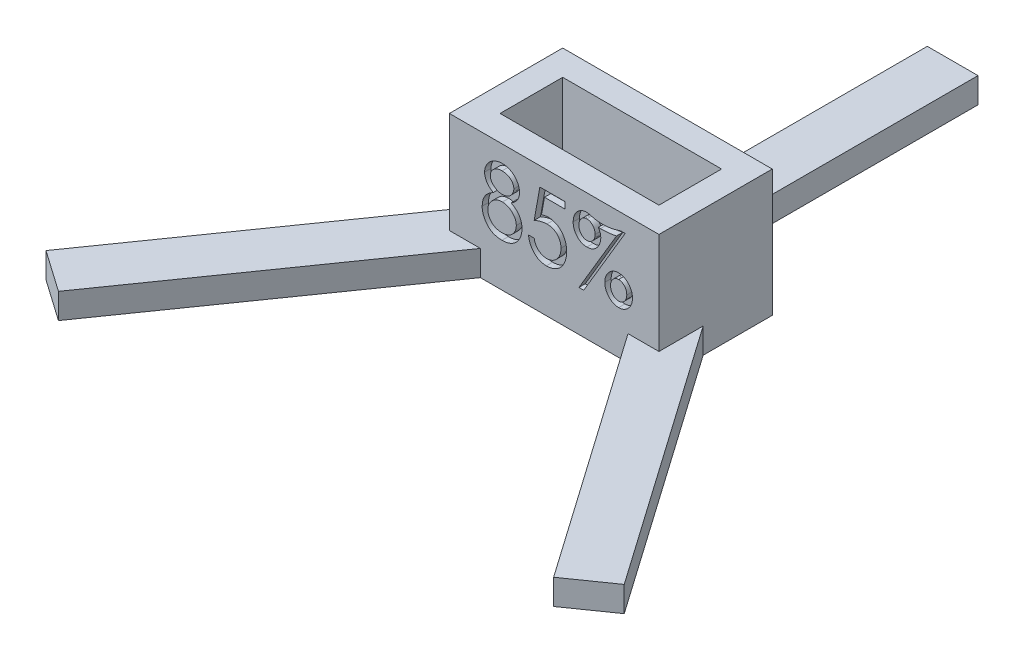
from build123d import *

# Parameters (mm, degrees)
SKETCH1_W             = 8
SKETCH1_H             = 45
BOSS_EXTRUDE1_DEPTH   = 4
BOSS_EXTRUDE1_2_DEPTH = 4
BOSS_EXTRUDE1_3_DEPTH = 4
SKETCH1_3_W           = 25.0698
SKETCH1_3_H           = 9.8806
BOSS_EXTRUDE2_DEPTH   = 20
CUT_EXTRUDE1_DEPTH    = 1


with BuildPart() as part:
    # Sketch1 → Boss-Extrude1 (new body)
    with BuildSketch(Plane(origin=(0, 0, 0), x_dir=(1, 0, 0), z_dir=(0, 1, 0))):
        with Locations((0, 31.4403)):
            Rectangle(SKETCH1_W, SKETCH1_H)
    extrude(amount=BOSS_EXTRUDE1_DEPTH)



with BuildPart() as body_2:
    # Sketch1 → Boss-Extrude1 2 (new body)
    with BuildSketch(Plane(origin=(0, 0, 0), x_dir=(1, 0, 0), z_dir=(0, 1, 0))):
        Polygon((-16.5349, -8.9403), (-16.5349, -1.966512818), (-45.622447813, -43.507836248), (-39.069231459, -48.096447738), (-11.651801645, -8.9403), align=None)
    extrude(amount=BOSS_EXTRUDE1_2_DEPTH)


with BuildPart() as body_3:
    # Sketch1 → Boss-Extrude1 3 (new body)
    with BuildSketch(Plane(origin=(0, 0, 0), x_dir=(1, 0, 0), z_dir=(0, 1, 0))):
        Polygon((45.622447813, -43.507836248), (16.5349, -1.966512818), (16.5349, -8.9403), (11.651801645, -8.9403), (39.069231459, -48.096447738), align=None)
    extrude(amount=BOSS_EXTRUDE1_3_DEPTH)


with BuildPart() as part_1:
    add(part.part)

    add(body_2.part)  # Boss-Extrude2 merges body 2

    add(body_3.part)  # Boss-Extrude2 merges body 3
    # Sketch1_3 → Boss-Extrude2 (add)
    with BuildSketch(Plane(origin=(0, 0, 0), x_dir=(1, 0, 0), z_dir=(0, 1, 0))):
        Polygon((-4, 8.9403), (-16.5349, 8.9403), (-16.5349, -1.966512818), (-16.5349, -8.9403), (-11.651801645, -8.9403), (11.651801645, -8.9403), (16.5349, -8.9403), (16.5349, -1.966512818), (16.5349, 8.9403), (4, 8.9403), align=None)
        Rectangle(SKETCH1_3_W, SKETCH1_3_H, mode=Mode.SUBTRACT)
    extrude(amount=BOSS_EXTRUDE2_DEPTH)

    # Sketch2 → Cut-Extrude1 (cut)
    # profile 1 of 4: a face of its own
    with BuildSketch(Plane.XY.offset(8.9403)):
        with BuildLine():
            add(Edge.make_bspline(
                [(-6.79314399, 12.649771541), (-6.717342821, 12.606981876), (-6.569116403, 12.523308248), (-6.358099072, 12.390611796), (-6.168281011, 12.247763488), (-5.990326983, 12.10806329), (-5.833426128, 11.958008496), (-5.69384615, 11.804486733), (-5.569455402, 11.647651561), (-5.431928233, 11.430856172), (-5.290676489, 11.145729516), (-5.166856952, 10.781790134), (-5.093651834, 10.393754983), (-5.084878424, 10.127380734), (-5.080403606, 9.991518336)],
                knots=[0, 0, 0, 0, 0.936542975, 1.831375574, 2.679144523, 3.491470365, 4.26389981, 5.011508052, 5.722891413, 6.414408021, 7.770248425, 9.135648072, 10.539056521, 12, 12, 12, 12], degree=3))
            add(Edge.make_bspline(
                [(-5.080403606, 9.991518336), (-5.081899375, 9.895244225), (-5.084859165, 9.704739536), (-5.121433878, 9.423690295), (-5.173934798, 9.150619568), (-5.25153255, 8.886238863), (-5.348322964, 8.630155498), (-5.471084701, 8.383936987), (-5.61165909, 8.144635704), (-5.723320139, 7.99534588), (-5.779522195, 7.920204233)],
                knots=[0, 0, 0, 0, 1.036424978, 2.050850602, 3.048199039, 4.029333599, 5.015202885, 5.993141774, 6.989893439, 8, 8, 8, 8], degree=3))
            add(Edge.make_bspline(
                [(-5.779522195, 7.920204233), (-5.853048351, 7.832942505), (-5.998529005, 7.660284312), (-6.248926024, 7.434473736), (-6.523979909, 7.244626836), (-6.822380899, 7.089899899), (-7.143229542, 6.969436448), (-7.486424218, 6.882861106), (-7.852726821, 6.833289668), (-8.104426454, 6.826121995), (-8.233448477, 6.822447823)],
                knots=[0, 0, 0, 0, 0.981131941, 1.941291689, 2.891287071, 3.849949701, 4.826493893, 5.834124351, 6.889765335, 8, 8, 8, 8], degree=3))
            add(Edge.make_bspline(
                [(-8.233448477, 6.822447823), (-8.357758165, 6.825769094), (-8.599837595, 6.832236904), (-8.951827599, 6.875291615), (-9.280150757, 6.952615089), (-9.587056124, 7.055191141), (-9.869512454, 7.192428296), (-10.127381592, 7.360610279), (-10.365085258, 7.555277126), (-10.572402784, 7.782690704), (-10.756881471, 8.025314606), (-10.918004948, 8.27678077), (-11.054779866, 8.533984287), (-11.16806958, 8.796890259), (-11.254214089, 9.066824902), (-11.316166757, 9.342278961), (-11.356193225, 9.623757239), (-11.360358672, 9.813766733), (-11.362454888, 9.909386925)],
                knots=[0, 0, 0, 0, 1.21096191, 2.358214982, 3.446884378, 4.49182925, 5.504198937, 6.49649756, 7.485058376, 8.488402548, 9.486228629, 10.451554982, 11.394331069, 12.321016062, 13.236400715, 14.150050479, 15.069033212, 16, 16, 16, 16], degree=3))
            add(Edge.make_bspline(
                [(-11.362454888, 9.909386925), (-11.357979159, 10.047911095), (-11.349201872, 10.319568828), (-11.275860259, 10.71619535), (-11.151526388, 11.089666503), (-11.011908354, 11.385521507), (-10.871219266, 11.609347488), (-10.745793796, 11.772933998), (-10.600744543, 11.93001289), (-10.439953765, 12.085826484), (-10.259741875, 12.234756225), (-10.061840718, 12.379963078), (-9.846051642, 12.520244233), (-9.692312765, 12.605931951), (-9.613656811, 12.649771541)],
                knots=[0, 0, 0, 0, 1.449072761, 2.841755515, 4.203119693, 5.559721925, 6.253850403, 6.966723721, 7.713721691, 8.489710117, 9.308452918, 10.158310275, 11.05775386, 12, 12, 12, 12], degree=3))
            add(Edge.make_bspline(
                [(-9.613656811, 12.649771541), (-9.721546601, 12.713300647), (-9.931900117, 12.83716381), (-10.210552362, 13.061044081), (-10.449486313, 13.305223447), (-10.642163586, 13.572526794), (-10.790957506, 13.856502582), (-10.898099184, 14.15151523), (-10.964991886, 14.457021292), (-10.973538318, 14.66466246), (-10.977839503, 14.769162567)],
                knots=[0, 0, 0, 0, 1.13273587, 2.208503431, 3.22641434, 4.218394485, 5.181414728, 6.120748945, 7.054224471, 8, 8, 8, 8], degree=3))
            add(Edge.make_bspline(
                [(-10.977839503, 14.769162567), (-10.972859065, 14.875672007), (-10.96286111, 15.089483876), (-10.891943087, 15.408228538), (-10.774158317, 15.721323692), (-10.613955995, 16.027114013), (-10.414515779, 16.316079533), (-10.173033371, 16.574221857), (-9.897963089, 16.801103234), (-9.590070232, 16.991311033), (-9.259256025, 17.146638844), (-8.909647289, 17.253491841), (-8.548051994, 17.323246669), (-8.301882969, 17.331229987), (-8.177358734, 17.335268336)],
                knots=[0, 0, 0, 0, 0.910776501, 1.828333955, 2.778985199, 3.765162585, 4.774507301, 5.772785072, 6.779119179, 7.815669498, 8.860886553, 9.896066783, 10.935728504, 12, 12, 12, 12], degree=3))
            add(Edge.make_bspline(
                [(-8.177358734, 17.335268336), (-8.056197479, 17.331126636), (-7.816702837, 17.322939902), (-7.464159268, 17.254608613), (-7.126533085, 17.141845264), (-6.805938071, 16.986952896), (-6.507701965, 16.796387809), (-6.241876755, 16.568719073), (-6.0108045, 16.308772563), (-5.816312046, 16.022201053), (-5.659529534, 15.716142652), (-5.546688189, 15.398399565), (-5.477621904, 15.071948153), (-5.469228609, 14.851621507), (-5.46501899, 14.741117695)],
                knots=[0, 0, 0, 0, 1.046778402, 2.069125308, 3.091390723, 4.116406946, 5.139600975, 6.142665277, 7.132132783, 8.137635919, 9.129004421, 10.096677816, 11.045397548, 12, 12, 12, 12], degree=3))
            add(Edge.make_bspline(
                [(-5.46501899, 14.741117695), (-5.468535113, 14.632628895), (-5.475433061, 14.419795054), (-5.53969705, 14.110024637), (-5.644106009, 13.818148346), (-5.792819528, 13.545730281), (-5.980297574, 13.290364961), (-6.213858156, 13.057428679), (-6.483553962, 12.83716416), (-6.687963312, 12.71343665), (-6.79314399, 12.649771541)],
                knots=[0, 0, 0, 0, 0.997542021, 1.95698265, 2.897938278, 3.841179291, 4.803666238, 5.803250932, 6.86964291, 8, 8, 8, 8], degree=3))
        make_face()
        with BuildLine():
            add(Edge.make_bspline(
                [(-8.225435657, 16.30962731), (-8.290912687, 16.307793004), (-8.418832269, 16.304209401), (-8.607363259, 16.284741015), (-8.786789674, 16.24829672), (-8.958559026, 16.199359777), (-9.119361587, 16.13079197), (-9.274759356, 16.054583034), (-9.419270673, 15.958680129), (-9.554596332, 15.851378111), (-9.677433576, 15.734816091), (-9.785032082, 15.611564723), (-9.875832665, 15.482753113), (-9.950617938, 15.34781485), (-10.008543785, 15.207208846), (-10.051704369, 15.061773971), (-10.075820301, 14.910199221), (-10.078861698, 14.807304836), (-10.080403606, 14.755140131)],
                knots=[0, 0, 0, 0, 1.167930736, 2.281734702, 3.374655602, 4.42968456, 5.460169067, 6.487966878, 7.511825295, 8.545812643, 9.564951514, 10.527197576, 11.458821733, 12.370211683, 13.272454276, 14.165535204, 15.069975329, 16, 16, 16, 16], degree=3))
            add(Edge.make_bspline(
                [(-10.080403606, 14.755140131), (-10.07930648, 14.702898692), (-10.077137612, 14.599624498), (-10.04620701, 14.447492299), (-10.00311841, 14.298611391), (-9.940331711, 14.153351836), (-9.858432485, 14.013042946), (-9.763483857, 13.873241147), (-9.644563208, 13.742150007), (-9.514888461, 13.612749445), (-9.372108199, 13.494122082), (-9.222058137, 13.388867515), (-9.063594914, 13.302354108), (-8.900658599, 13.230859361), (-8.73202489, 13.17326283), (-8.557436941, 13.133844185), (-8.376395357, 13.108931668), (-8.25356236, 13.10598884), (-8.19138117, 13.104499105)],
                knots=[0, 0, 0, 0, 0.905852599, 1.790746938, 2.68614417, 3.595331889, 4.530413024, 5.505287501, 6.52435105, 7.598740087, 8.685763206, 9.744258785, 10.777285004, 11.815960297, 12.831917038, 13.867284544, 14.920365135, 16, 16, 16, 16], degree=3))
            add(Edge.make_bspline(
                [(-8.19138117, 13.104499105), (-8.111708856, 13.106992232), (-7.953124773, 13.111954687), (-7.719678808, 13.158153552), (-7.493148145, 13.230803817), (-7.27570659, 13.33063158), (-7.072220968, 13.455259411), (-6.890792855, 13.60477498), (-6.732127815, 13.774513192), (-6.601431068, 13.964627728), (-6.496904861, 14.164167678), (-6.418065635, 14.366544508), (-6.37304163, 14.570876173), (-6.365960138, 14.707530159), (-6.362454888, 14.775172182)],
                knots=[0, 0, 0, 0, 1.04622229, 2.082457431, 3.114969114, 4.167467583, 5.219673264, 6.242289877, 7.248351568, 8.263597399, 9.264670006, 10.203562472, 11.110785765, 12, 12, 12, 12], degree=3))
            add(Edge.make_bspline(
                [(-6.362454888, 14.775172182), (-6.3641065, 14.822667741), (-6.367380897, 14.916829819), (-6.390200437, 15.05580787), (-6.426642996, 15.1921878), (-6.478473004, 15.32614402), (-6.547380443, 15.456494578), (-6.630476918, 15.583419293), (-6.727281693, 15.708273694), (-6.837850487, 15.829633454), (-6.963707586, 15.941523354), (-7.103491006, 16.041321482), (-7.257743559, 16.124734447), (-7.425526743, 16.193670259), (-7.606607653, 16.244536555), (-7.800679409, 16.28347665), (-8.00861999, 16.304661649), (-8.15194132, 16.307944092), (-8.225435657, 16.30962731)],
                knots=[0, 0, 0, 0, 0.846273469, 1.677775159, 2.503379903, 3.358642367, 4.231605182, 5.126121923, 6.059228345, 7.044670925, 8.047775682, 9.054896115, 10.098683671, 11.166083855, 12.28092389, 13.445529808, 14.69008269, 16, 16, 16, 16], degree=3))
        make_face(mode=Mode.SUBTRACT)
        with BuildLine():
            add(Edge.make_bspline(
                [(-8.173352323, 12.078858079), (-8.252943304, 12.077246118), (-8.409460541, 12.074076166), (-8.63847039, 12.039795405), (-8.858953053, 11.990812716), (-9.069632841, 11.919047228), (-9.269320925, 11.822899602), (-9.460138119, 11.709573911), (-9.639379398, 11.573033466), (-9.808307448, 11.420837973), (-9.960501335, 11.253430919), (-10.096903695, 11.079358725), (-10.208271089, 10.895214911), (-10.304418314, 10.706825431), (-10.376683093, 10.509673877), (-10.425776592, 10.305168193), (-10.46006939, 10.094829751), (-10.463359383, 9.951593218), (-10.46501899, 9.879338849)],
                knots=[0, 0, 0, 0, 1.081539399, 2.126868595, 3.142349074, 4.150290619, 5.145429903, 6.15144715, 7.163022546, 8.204479408, 9.239224426, 10.236350348, 11.206610885, 12.160933525, 13.108971242, 14.05378537, 15.018249692, 16, 16, 16, 16], degree=3))
            add(Edge.make_bspline(
                [(-10.46501899, 9.879338849), (-10.461505994, 9.78960063), (-10.454550832, 9.611933517), (-10.399881309, 9.349091934), (-10.311803425, 9.094500134), (-10.188906577, 8.850374773), (-10.037544954, 8.621618915), (-9.848906243, 8.422753551), (-9.638593461, 8.245565143), (-9.397695534, 8.102193712), (-9.134341697, 7.986400334), (-8.847847127, 7.908894096), (-8.543232965, 7.855824547), (-8.3331824, 7.850711578), (-8.225435657, 7.848088849)],
                knots=[0, 0, 0, 0, 0.953900318, 1.888567877, 2.843208308, 3.812011761, 4.789111247, 5.749021607, 6.71753862, 7.705420928, 8.720131869, 9.767960352, 10.855061389, 12, 12, 12, 12], degree=3))
            add(Edge.make_bspline(
                [(-8.225435657, 7.848088849), (-8.141874797, 7.849932222), (-7.978198582, 7.85354296), (-7.739458936, 7.884116341), (-7.513247802, 7.933862681), (-7.300885756, 8.004505174), (-7.100009812, 8.09171514), (-6.915686158, 8.20420135), (-6.74096948, 8.331772953), (-6.58523011, 8.482559344), (-6.443198593, 8.644061345), (-6.318545232, 8.814050961), (-6.214158896, 8.991627178), (-6.126895253, 9.174156444), (-6.060751405, 9.364461895), (-6.012325822, 9.56083623), (-5.983907754, 9.764996797), (-5.979882683, 9.90328999), (-5.977839503, 9.97348949)],
                knots=[0, 0, 0, 0, 1.159357446, 2.270910543, 3.334408313, 4.368922933, 5.372934548, 6.366282269, 7.359759672, 8.369273697, 9.367494498, 10.342516416, 11.289792923, 12.222542171, 13.145805194, 14.080853556, 15.025815257, 16, 16, 16, 16], degree=3))
            add(Edge.make_bspline(
                [(-5.977839503, 9.97348949), (-5.97967542, 10.041718102), (-5.983293659, 10.176183595), (-6.014836669, 10.374845217), (-6.064553677, 10.567632297), (-6.135393126, 10.754819812), (-6.225680497, 10.936694727), (-6.339302593, 11.110370561), (-6.46981, 11.279925017), (-6.619308676, 11.440079151), (-6.781270345, 11.590076001), (-6.955989884, 11.719607596), (-7.137569772, 11.831849629), (-7.328611352, 11.921813485), (-7.527914521, 11.992421876), (-7.735978969, 12.042545195), (-7.952083393, 12.073186122), (-8.099133817, 12.076955579), (-8.173352323, 12.078858079)],
                knots=[0, 0, 0, 0, 0.971444992, 1.914531533, 2.858193596, 3.803436534, 4.760618253, 5.744833788, 6.755181074, 7.805273357, 8.86236533, 9.895429839, 10.898766981, 11.898716369, 12.897579249, 13.905819635, 14.943036437, 16, 16, 16, 16], degree=3))
        make_face(mode=Mode.SUBTRACT)
    # profile 2 of 4: a face of its own
    with BuildSketch(Plane.XY.offset(8.9403)):
        with BuildLine():
            Line((1.714468189, 17.078858079), (1.714468189, 16.053217054))
            Line((1.714468189, 16.053217054), (-1.528720913, 16.053217054))
            Line((-1.528720913, 16.053217054), (-2.001477323, 13.429018336))
            add(Edge.make_bspline(
                [(-2.001477323, 13.429018336), (-1.90430502, 13.457582178), (-1.716013869, 13.512930446), (-1.437900942, 13.573784027), (-1.173739553, 13.60918937), (-1.002640679, 13.614666199), (-0.919746554, 13.617319618)],
                knots=[0, 0, 0, 0, 1.102707905, 2.136721407, 3.097277234, 4, 4, 4, 4], degree=3))
            add(Edge.make_bspline(
                [(-0.919746554, 13.617319618), (-0.816736219, 13.614967598), (-0.615066104, 13.610362895), (-0.319849896, 13.564062831), (-0.038329361, 13.492730917), (0.229663519, 13.391825494), (0.484295704, 13.26323882), (0.723294574, 13.10333747), (0.949507245, 12.915983341), (1.15786181, 12.69958041), (1.348984333, 12.46345469), (1.517295425, 12.209160788), (1.65705724, 11.938051125), (1.772017357, 11.650871808), (1.862303964, 11.347875642), (1.925780897, 11.028007262), (1.964787874, 10.692278761), (1.968820735, 10.463047596), (1.970878446, 10.346085643)],
                knots=[0, 0, 0, 0, 1.010628668, 1.97857427, 2.926238053, 3.857732153, 4.784206679, 5.720601656, 6.674976368, 7.662461082, 8.664805768, 9.653942959, 10.650870456, 11.653986639, 12.686928979, 13.750194809, 14.852068795, 16, 16, 16, 16], degree=3))
            add(Edge.make_bspline(
                [(1.970878446, 10.346085643), (1.965977564, 10.184189043), (1.956319252, 9.865134681), (1.876691617, 9.39726742), (1.742813832, 8.950587004), (1.590207339, 8.596419511), (1.442760067, 8.329704314), (1.324942499, 8.140211568), (1.196199071, 7.96421349), (1.059966488, 7.798781844), (0.913238259, 7.646190229), (0.756642199, 7.505488323), (0.590191173, 7.377464432), (0.415398023, 7.261268939), (0.233763192, 7.155894646), (0.042207466, 7.069117587), (-0.154488531, 6.991615562), (-0.358961245, 6.930154716), (-0.569753259, 6.881659643), (-0.787422264, 6.848581542), (-1.012029717, 6.824634201), (-1.164738882, 6.823184017), (-1.24226258, 6.822447823)],
                knots=[0, 0, 0, 0, 1.817942315, 3.582672045, 5.312817344, 7.046390462, 7.902497116, 8.735010984, 9.551245316, 10.350340788, 11.14083426, 11.92700933, 12.713220188, 13.497567984, 14.283778841, 15.069130373, 15.857592503, 16.657286298, 17.465240455, 18.285360574, 19.129553296, 20, 20, 20, 20], degree=3))
            add(Edge.make_bspline(
                [(-1.24226258, 6.822447823), (-1.333899524, 6.824448319), (-1.51465353, 6.828394301), (-1.779245502, 6.86885474), (-2.034256198, 6.927433085), (-2.277406261, 7.015112672), (-2.511339199, 7.124640972), (-2.731542947, 7.262505215), (-2.942226961, 7.421843233), (-3.139105541, 7.605469321), (-3.320238522, 7.809603204), (-3.485308052, 8.028086198), (-3.630569952, 8.261870526), (-3.754128346, 8.510450465), (-3.858948936, 8.773182373), (-3.944976623, 9.049690479), (-4.011352848, 9.341171523), (-4.040128616, 9.541223751), (-4.05476258, 9.642960643)],
                knots=[0, 0, 0, 0, 1.003116473, 1.978648716, 2.926104392, 3.865449161, 4.804537555, 5.750523693, 6.705881415, 7.694490351, 8.694401117, 9.692169023, 10.690874996, 11.704999753, 12.729205104, 13.786546159, 14.874344384, 16, 16, 16, 16], degree=3))
            Line((-4.05476258, 9.642960643), (-3.157326682, 9.642960643))
            add(Edge.make_bspline(
                [(-3.157326682, 9.642960643), (-3.137743706, 9.547701349), (-3.100206545, 9.365105845), (-3.017392655, 9.107815566), (-2.915800349, 8.878423403), (-2.794520701, 8.674864181), (-2.65187142, 8.494675692), (-2.485567344, 8.337806021), (-2.302920355, 8.192146973), (-2.09701375, 8.073497216), (-1.880984452, 7.971432521), (-1.654632251, 7.903040037), (-1.424549752, 7.855274998), (-1.268549209, 7.850491789), (-1.190179247, 7.848088849)],
                knots=[0, 0, 0, 0, 1.202539977, 2.305060038, 3.336811461, 4.300249956, 5.229209465, 6.169887062, 7.123427807, 8.112385324, 9.103101112, 10.072507195, 11.031685809, 12, 12, 12, 12], degree=3))
            add(Edge.make_bspline(
                [(-1.190179247, 7.848088849), (-1.113917298, 7.850452324), (-0.963298584, 7.85512023), (-0.741876429, 7.890632632), (-0.528151514, 7.945266471), (-0.324923106, 8.028417257), (-0.12626271, 8.126442496), (0.059144689, 8.256332747), (0.241426905, 8.40131957), (0.409202511, 8.571796), (0.565186907, 8.756450401), (0.702444644, 8.955199061), (0.816118186, 9.166809939), (0.911824364, 9.388140416), (0.98309757, 9.621576666), (1.035190624, 9.865482539), (1.068517404, 10.120806604), (1.071779635, 10.295233093), (1.073442548, 10.384146541)],
                knots=[0, 0, 0, 0, 0.966892467, 1.909629934, 2.8382218, 3.758315477, 4.690146358, 5.641556776, 6.623066209, 7.641204016, 8.669263481, 9.686520165, 10.698438552, 11.711596797, 12.740318951, 13.788555981, 14.872722182, 16, 16, 16, 16], degree=3))
            add(Edge.make_bspline(
                [(1.073442548, 10.384146541), (1.071475376, 10.464363213), (1.067626983, 10.621291665), (1.038822854, 10.850477032), (0.993655832, 11.06813315), (0.927079898, 11.27430383), (0.840235432, 11.468122053), (0.738301242, 11.65252167), (0.615154602, 11.82385519), (0.472534628, 11.98065131), (0.317532675, 12.125864632), (0.146343192, 12.250468833), (-0.038082379, 12.354200737), (-0.232464382, 12.444734308), (-0.442533126, 12.508985951), (-0.663457401, 12.557831999), (-0.897007289, 12.585644169), (-1.056562108, 12.589637809), (-1.138095913, 12.591678592)],
                knots=[0, 0, 0, 0, 1.093612449, 2.139441871, 3.144892665, 4.12105543, 5.08718674, 6.037047387, 6.989697133, 7.956857702, 8.923418003, 9.881405251, 10.835750608, 11.805607787, 12.799113192, 13.824284988, 14.888192007, 16, 16, 16, 16], degree=3))
            add(Edge.make_bspline(
                [(-1.138095913, 12.591678592), (-1.209606935, 12.59006207), (-1.356346481, 12.586744991), (-1.581780984, 12.561046444), (-1.817876231, 12.521089125), (-2.065104964, 12.464118015), (-2.323167043, 12.392063877), (-2.592192486, 12.302944002), (-2.872447857, 12.199385682), (-3.060813436, 12.119691266), (-3.157326682, 12.078858079)],
                knots=[0, 0, 0, 0, 0.81831526, 1.679170654, 2.59384348, 3.557915884, 4.581464615, 5.659350651, 6.800716828, 8, 8, 8, 8], degree=3))
            Line((-3.157326682, 12.078858079), (-2.259890785, 17.078858079))
            Line((-2.259890785, 17.078858079), (1.714468189, 17.078858079))
        make_face()
    # profile 3 of 4: a face of its own
    with BuildSketch(Plane.XY.offset(8.9403)):
        with BuildLine():
            Line((11.201647677, 17.463473464), (4.663186138, 6.437832438))
            Line((4.663186138, 6.437832438), (3.903971394, 6.437832438))
            Line((3.903971394, 6.437832438), (9.845477805, 16.453858079))
            add(Edge.make_bspline(
                [(9.845477805, 16.453858079), (9.75688223, 16.431518488), (9.575308844, 16.385734314), (9.292508186, 16.334264674), (8.997018565, 16.284700355), (8.686105922, 16.247631872), (8.361539422, 16.216954837), (8.022028585, 16.1987271), (7.668808352, 16.182827787), (7.428297516, 16.181897495), (7.305413702, 16.181422182)],
                knots=[0, 0, 0, 0, 0.855912764, 1.754161863, 2.692276577, 3.66314188, 4.687322541, 5.746584714, 6.848666156, 8, 8, 8, 8], degree=3))
            Line((7.305413702, 16.181422182), (6.96486883, 16.187431797))
            add(Edge.make_bspline(
                [(6.96486883, 16.187431797), (7.024651477, 16.091524452), (7.141735517, 15.903690356), (7.263633321, 15.598419432), (7.342312218, 15.285312212), (7.351099066, 15.072110192), (7.35549383, 14.965476669)],
                knots=[0, 0, 0, 0, 1.040152756, 2.037134388, 3.018267853, 4, 4, 4, 4], degree=3))
            add(Edge.make_bspline(
                [(7.35549383, 14.965476669), (7.353435627, 14.88993817), (7.349341624, 14.73968338), (7.320663929, 14.517828514), (7.274539045, 14.301192776), (7.208998809, 14.090870289), (7.12114975, 13.88824989), (7.018762512, 13.689929699), (6.896820512, 13.497624932), (6.755028918, 13.315531009), (6.601590732, 13.145043681), (6.43059455, 12.997699939), (6.249737759, 12.870619498), (6.053517423, 12.770040102), (5.847827911, 12.689181124), (5.628426693, 12.633421156), (5.397473181, 12.59864171), (5.238900363, 12.594031344), (5.157977805, 12.591678592)],
                knots=[0, 0, 0, 0, 1.005575621, 2.000205929, 2.973185489, 3.951673136, 4.927572614, 5.90972857, 6.920908292, 7.954047531, 8.979662321, 9.969034214, 10.952999114, 11.915278637, 12.897595523, 13.889480591, 14.922964025, 16, 16, 16, 16], degree=3))
            add(Edge.make_bspline(
                [(5.157977805, 12.591678592), (5.083066899, 12.593360514), (4.935865633, 12.59666552), (4.71965698, 12.630035664), (4.512479854, 12.683426505), (4.315028034, 12.761097654), (4.125449699, 12.856779573), (3.946057444, 12.97671146), (3.775833419, 13.117205833), (3.616503895, 13.277095881), (3.470898977, 13.451625858), (3.345192438, 13.639137714), (3.234892812, 13.833447464), (3.149375288, 14.039935341), (3.081471894, 14.254483203), (3.030065884, 14.477970812), (3.002824327, 14.711055725), (2.998640292, 14.869259858), (2.996519471, 14.949451028)],
                knots=[0, 0, 0, 0, 1.008398907, 1.981521851, 2.939267593, 3.884685526, 4.834031687, 5.794476735, 6.784904661, 7.802527834, 8.83094575, 9.841308357, 10.839871351, 11.835513377, 12.845355375, 13.868765724, 14.919711099, 16, 16, 16, 16], degree=3))
            add(Edge.make_bspline(
                [(2.996519471, 14.949451028), (3.000007433, 15.056508295), (3.006873234, 15.267242822), (3.060396608, 15.575236968), (3.146238185, 15.868106916), (3.267640762, 16.14350992), (3.418010641, 16.40032385), (3.603567009, 16.630149021), (3.814235292, 16.837262116), (4.054335257, 17.010350331), (4.307193071, 17.155396712), (4.569959751, 17.25752285), (4.835480646, 17.324243364), (5.014698044, 17.331604722), (5.103891266, 17.335268336)],
                knots=[0, 0, 0, 0, 1.092215168, 2.149946973, 3.180744331, 4.200099484, 5.214681398, 6.208844029, 7.206551423, 8.220766995, 9.221704991, 10.173472071, 11.090970441, 12, 12, 12, 12], degree=3))
            add(Edge.make_bspline(
                [(5.103891266, 17.335268336), (5.148049067, 17.332714136), (5.249678302, 17.326835643), (5.419367892, 17.295782336), (5.62613096, 17.25014249), (5.774514428, 17.207943735), (5.855093189, 17.185027951)],
                knots=[0, 0, 0, 0, 0.690746528, 1.589753997, 2.691130206, 4, 4, 4, 4], degree=3))
            add(Edge.make_bspline(
                [(5.855093189, 17.185027951), (5.990841103, 17.14889161), (6.26551708, 17.075772366), (6.691698616, 17.003516127), (7.13412693, 16.957811272), (7.434836062, 16.953067192), (7.587865625, 16.950652951)],
                knots=[0, 0, 0, 0, 0.960518299, 1.943538547, 2.953475758, 4, 4, 4, 4], degree=3))
            add(Edge.make_bspline(
                [(7.587865625, 16.950652951), (7.701420716, 16.951509364), (7.924709447, 16.95319337), (8.254636187, 16.975383063), (8.574995883, 17.003636279), (8.895386998, 17.049088548), (9.233505611, 17.11599988), (9.607523476, 17.206982533), (10.027466006, 17.324155582), (10.321141982, 17.415274432), (10.47648742, 17.463473464)],
                knots=[0, 0, 0, 0, 0.924375097, 1.817642348, 2.691321289, 3.542448545, 4.450874239, 5.49655074, 6.675753369, 8, 8, 8, 8], degree=3))
            Line((10.47648742, 17.463473464), (11.201647677, 17.463473464))
        make_face()
        with BuildLine():
            add(Edge.make_bspline(
                [(5.174003446, 16.437832438), (5.087878694, 16.432387168), (4.918417005, 16.421672888), (4.674485007, 16.337206283), (4.452629596, 16.197659233), (4.2589393, 16.006578404), (4.098029998, 15.780710215), (3.979336482, 15.527155337), (3.907272314, 15.250527732), (3.898466301, 15.05805987), (3.893955369, 14.959467054)],
                knots=[0, 0, 0, 0, 0.951178476, 1.871567791, 2.820592491, 3.828833882, 4.861882757, 5.873123466, 6.91049474, 8, 8, 8, 8], degree=3))
            add(Edge.make_bspline(
                [(3.893955369, 14.959467054), (3.898356753, 14.860837012), (3.906920017, 14.668943958), (3.98030103, 14.392850377), (4.096834226, 14.138831912), (4.25927635, 13.914597668), (4.451949515, 13.724383274), (4.676131947, 13.591113468), (4.917725629, 13.501944262), (5.087741994, 13.493432908), (5.174003446, 13.48911449)],
                knots=[0, 0, 0, 0, 1.09192248, 2.124427164, 3.144622361, 4.173937012, 5.179276371, 6.122653022, 7.047487717, 8, 8, 8, 8], degree=3))
            add(Edge.make_bspline(
                [(5.174003446, 13.48911449), (5.260241018, 13.493469281), (5.430210316, 13.502052324), (5.671608898, 13.590493591), (5.894429215, 13.725647462), (6.088795192, 13.9143081), (6.252910047, 14.138784928), (6.372132959, 14.392355684), (6.444960996, 14.66900266), (6.453611638, 14.860856941), (6.458057933, 14.959467054)],
                knots=[0, 0, 0, 0, 0.951739036, 1.875822953, 2.812113807, 3.82198859, 4.854794862, 5.87729744, 6.908963939, 8, 8, 8, 8], degree=3))
            add(Edge.make_bspline(
                [(6.458057933, 14.959467054), (6.453501832, 15.058039551), (6.444607645, 15.250467748), (6.373103549, 15.527657695), (6.251704361, 15.780742637), (6.089140554, 16.006874673), (5.893724248, 16.196384427), (5.673264443, 16.337817623), (5.429516877, 16.421563869), (5.260103595, 16.432350432), (5.174003446, 16.437832438)],
                knots=[0, 0, 0, 0, 1.088619988, 2.125148351, 3.138716664, 4.175218747, 5.187953588, 6.129952941, 7.049594399, 8, 8, 8, 8], degree=3))
        make_face(mode=Mode.SUBTRACT)
    # profile 4 of 4: a face of its own
    with BuildSketch(Plane.XY.offset(8.9403)):
        with BuildLine():
            add(Edge.make_bspline(
                [(10.176006651, 11.566037567), (10.24960697, 11.564502446), (10.395623514, 11.561456904), (10.609548109, 11.525358702), (10.816019048, 11.471940278), (11.013482088, 11.394999395), (11.202956733, 11.296314833), (11.383287507, 11.174895472), (11.55757045, 11.034059286), (11.718904701, 10.870712224), (11.86809549, 10.694244349), (12.000191424, 10.507587384), (12.107523668, 10.309512233), (12.199227487, 10.104477202), (12.268962849, 9.889478945), (12.31919447, 9.665543311), (12.349898773, 9.432810597), (12.353612424, 9.274464055), (12.35549383, 9.194242695)],
                knots=[0, 0, 0, 0, 0.986039861, 1.956216137, 2.901059252, 3.842288536, 4.791534564, 5.760139168, 6.753107791, 7.791550277, 8.833769631, 9.849808566, 10.851780974, 11.850105389, 12.858221254, 13.877097411, 14.92449729, 16, 16, 16, 16], degree=3))
            add(Edge.make_bspline(
                [(12.35549383, 9.194242695), (12.353612573, 9.114021237), (12.349899217, 8.955674504), (12.319192768, 8.722943186), (12.268969017, 8.499002434), (12.199204802, 8.28402294), (12.107607581, 8.078918585), (11.999612395, 7.880621594), (11.868653842, 7.692567209), (11.719631927, 7.515639739), (11.556101305, 7.354776403), (11.384701482, 7.211021846), (11.202197764, 7.092616448), (11.013595917, 6.993323477), (10.815988566, 6.916588632), (10.609556491, 6.863114721), (10.395621356, 6.827031568), (10.249606247, 6.823983976), (10.176006651, 6.822447823)],
                knots=[0, 0, 0, 0, 1.075383163, 2.122666619, 3.141429524, 4.149433332, 5.147646778, 6.149507813, 7.172785576, 8.214889083, 9.2469043, 10.245438947, 11.208998036, 12.158138551, 13.099263214, 14.044001305, 15.014069742, 16, 16, 16, 16], degree=3))
            add(Edge.make_bspline(
                [(10.176006651, 6.822447823), (10.102407055, 6.823983976), (9.956391946, 6.827031568), (9.742456811, 6.863114721), (9.536024736, 6.916588632), (9.338417385, 6.993323477), (9.149815538, 7.092616448), (8.96731182, 7.211021846), (8.795911996, 7.354776403), (8.632381374, 7.515639739), (8.483359459, 7.692567209), (8.352400906, 7.880621594), (8.24440572, 8.078918585), (8.152808499, 8.28402294), (8.083044285, 8.499002434), (8.032820534, 8.722943186), (8.002114085, 8.955674504), (7.998400728, 9.114021237), (7.996519471, 9.194242695)],
                knots=[0, 0, 0, 0, 0.985930258, 1.955998695, 2.900736786, 3.841861449, 4.791001964, 5.754561053, 6.7530957, 7.785110917, 8.827214424, 9.850492187, 10.852353222, 11.850566668, 12.858570476, 13.877333381, 14.924616837, 16, 16, 16, 16], degree=3))
            add(Edge.make_bspline(
                [(7.996519471, 9.194242695), (7.998400878, 9.274464055), (8.002114529, 9.432810597), (8.032818832, 9.665543311), (8.083050452, 9.889478945), (8.152785814, 10.104477202), (8.244489633, 10.309512233), (8.351821877, 10.507587384), (8.483917812, 10.694244349), (8.633108601, 10.870712224), (8.794442852, 11.034059286), (8.968725795, 11.174895472), (9.149056568, 11.296314833), (9.338531214, 11.394999395), (9.535994254, 11.471940278), (9.742465192, 11.525358702), (9.956389787, 11.561456904), (10.102406331, 11.564502446), (10.176006651, 11.566037567)],
                knots=[0, 0, 0, 0, 1.07550271, 2.122902589, 3.141778746, 4.149894611, 5.148219026, 6.150191434, 7.166230369, 8.208449723, 9.246892209, 10.239860832, 11.208465436, 12.157711464, 13.098940748, 14.043783863, 15.013960139, 16, 16, 16, 16], degree=3))
        make_face()
        with BuildLine():
            add(Edge.make_bspline(
                [(10.174003446, 10.668601669), (10.087768185, 10.664240482), (9.917803442, 10.655644833), (9.675497945, 10.566976812), (9.452565287, 10.430982515), (9.259164234, 10.241284805), (9.0968978, 10.016827422), (8.979888193, 9.762316914), (8.90716615, 9.485357883), (8.89843034, 9.292853976), (8.893955369, 9.194242695)],
                knots=[0, 0, 0, 0, 0.951201534, 1.874763567, 2.820692533, 3.824648448, 4.852546663, 5.871337972, 6.909580111, 8, 8, 8, 8], degree=3))
            add(Edge.make_bspline(
                [(8.893955369, 9.194242695), (8.89843034, 9.095631414), (8.90716615, 8.903127506), (8.979888193, 8.626168475), (9.0968978, 8.371657967), (9.259164234, 8.147200584), (9.452565287, 7.957502874), (9.675497945, 7.821508578), (9.917803442, 7.732840556), (10.087768185, 7.724244907), (10.174003446, 7.71988372)],
                knots=[0, 0, 0, 0, 1.090419889, 2.128662028, 3.147453337, 4.175351552, 5.179307467, 6.125236433, 7.048798466, 8, 8, 8, 8], degree=3))
            add(Edge.make_bspline(
                [(10.174003446, 7.71988372), (10.260214523, 7.724281365), (10.430131603, 7.73294887), (10.672248254, 7.8208892), (10.893804731, 7.95877103), (11.088909106, 8.146909489), (11.252846245, 8.371611188), (11.37255032, 8.625671868), (11.444714564, 8.90318635), (11.453538049, 9.095651346), (11.458057933, 9.194242695)],
                knots=[0, 0, 0, 0, 0.950427341, 1.873237676, 2.812111347, 3.820594311, 4.851977159, 5.873070514, 6.910467616, 8, 8, 8, 8], degree=3))
            add(Edge.make_bspline(
                [(11.458057933, 9.194242695), (11.453538049, 9.292834043), (11.444714564, 9.485299039), (11.37255032, 9.762813521), (11.252846245, 10.016874201), (11.088909106, 10.2415759), (10.893804731, 10.429714359), (10.672248254, 10.56759619), (10.430131603, 10.655536519), (10.260214523, 10.664204024), (10.174003446, 10.668601669)],
                knots=[0, 0, 0, 0, 1.089532384, 2.126929486, 3.148022841, 4.179405689, 5.187888653, 6.126762324, 7.049572659, 8, 8, 8, 8], degree=3))
        make_face(mode=Mode.SUBTRACT)
    extrude(amount=-CUT_EXTRUDE1_DEPTH, mode=Mode.SUBTRACT)


solid = part_1.part
